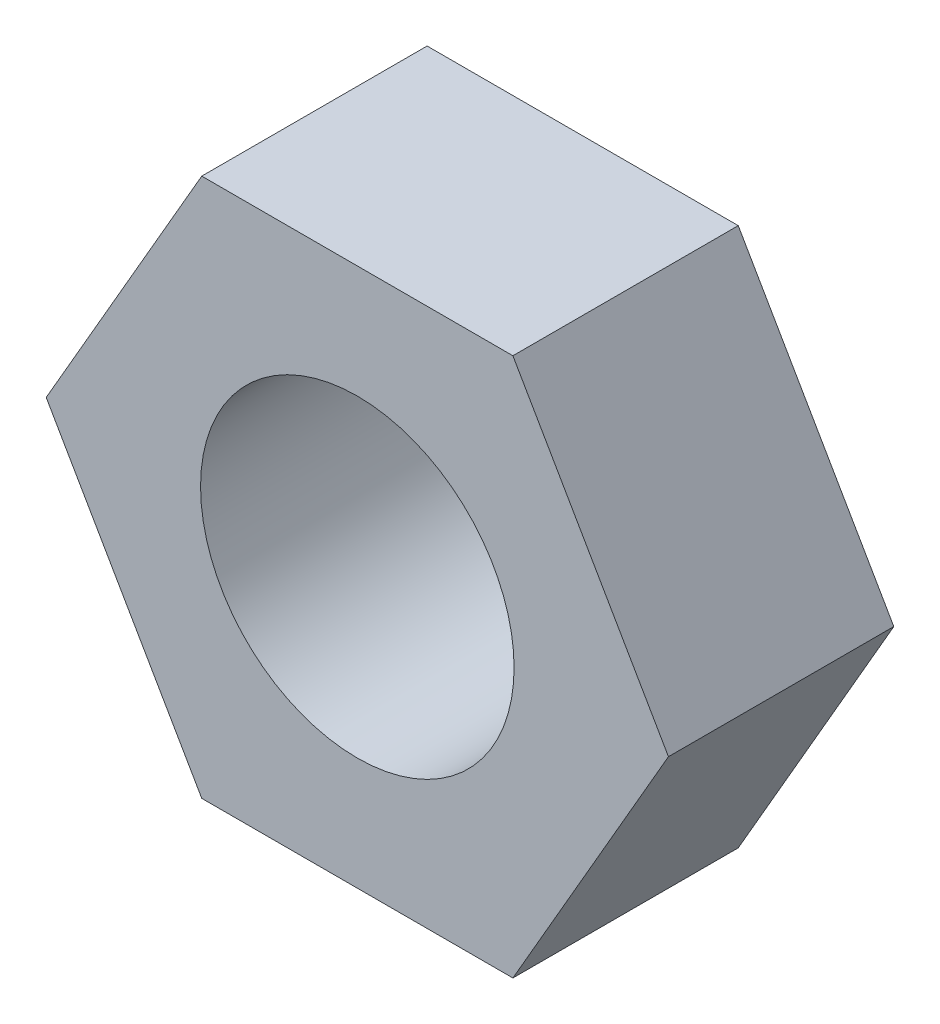
from build123d import *

# Parameters (mm, degrees)
BOSS_EXTRUDE1_DEPTH = 4.564
SKETCH2_R           = 3.175
CUT_EXTRUDE1_DEPTH  = 4.564


with BuildPart() as part:
    # Sketch1 → Boss-Extrude1 (new body)
    with BuildSketch(Plane.XY):
        Polygon((6.301200838, 0), (3.150600419, 5.457), (-3.150600419, 5.457), (-6.301200838, 0), (-3.150600419, -5.457), (3.150600419, -5.457), align=None)
    extrude(amount=BOSS_EXTRUDE1_DEPTH)

    # Sketch2 → Cut-Extrude1 (cut)
    with BuildSketch(Plane.XY.offset(4.564)):
        Circle(SKETCH2_R)
    extrude(amount=-CUT_EXTRUDE1_DEPTH, mode=Mode.SUBTRACT)


solid = part.part
